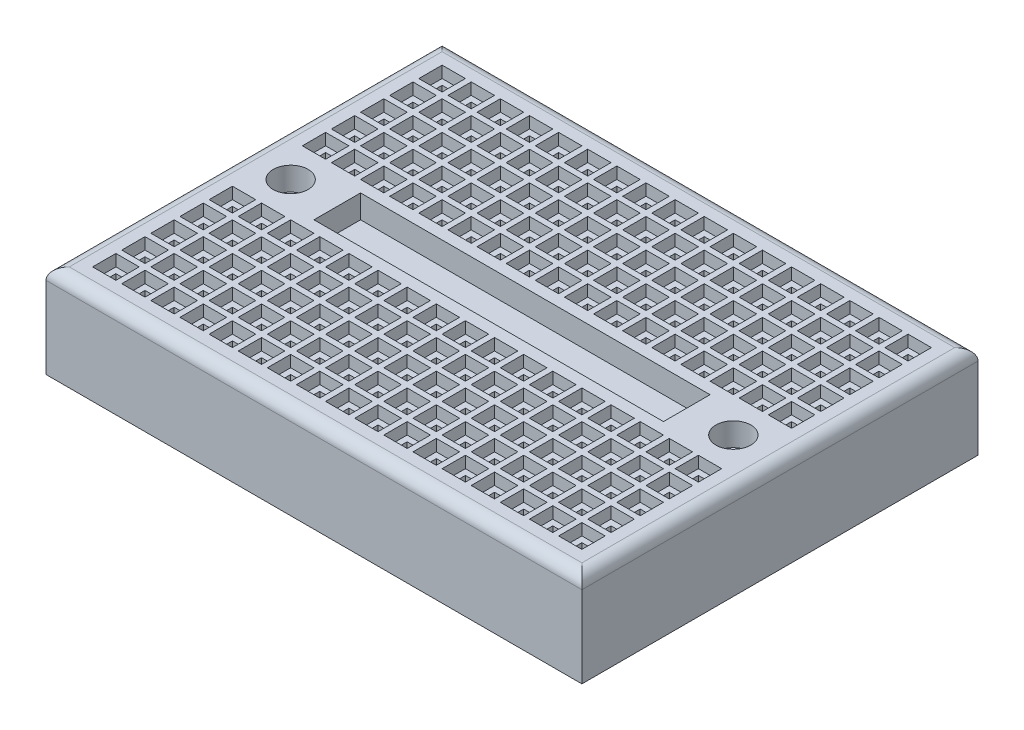
from build123d import *

# Parameters (mm, degrees)
SKETCH1_W           = 46
SKETCH1_H           = 34
BOSS_EXTRUDE1_DEPTH = 8
SKETCH2_W           = 30
SKETCH2_H           = 4
CUT_EXTRUDE1_DEPTH  = 2
SKETCH3_R           = 1.5
CUT_EXTRUDE2_DEPTH  = 2
SKETCH4_R           = 1
CUT_EXTRUDE3_DEPTH  = 12
FILLET1_R           = 1
SKETCH5_W           = 2
SKETCH5_H           = 2
CUT_EXTRUDE4_DEPTH  = 1
SKETCH6_W           = 1
SKETCH6_H           = 1
CUT_EXTRUDE5_DEPTH  = 5


with BuildPart() as part:
    # Sketch1 → Boss-Extrude1 (new body)
    with BuildSketch(Plane(origin=(0, 0, 0), x_dir=(1, 0, 0), z_dir=(0, 1, 0))):
        Rectangle(SKETCH1_W, SKETCH1_H)
    extrude(amount=BOSS_EXTRUDE1_DEPTH)

    # Sketch2 → Cut-Extrude1 (cut)
    with BuildSketch(Plane(origin=(0, 8, 0), x_dir=(1, 0, 0), z_dir=(0, 1, 0))):
        Rectangle(SKETCH2_W, SKETCH2_H)
    extrude(amount=-CUT_EXTRUDE1_DEPTH, mode=Mode.SUBTRACT)

    # Sketch3 → Cut-Extrude2 (cut)
    with BuildSketch(Plane(origin=(0, 8, 0), x_dir=(1, 0, 0), z_dir=(0, 1, 0))):
        with Locations((-19, 0)):
            Circle(SKETCH3_R)
        with Locations((19, 0)):
            Circle(SKETCH3_R)
    extrude(amount=-CUT_EXTRUDE2_DEPTH, mode=Mode.SUBTRACT)

    # Sketch4 → Cut-Extrude3 (cut)
    with BuildSketch(Plane(origin=(0, 6, 0), x_dir=(1, 0, 0), z_dir=(0, 1, 0))):
        with Locations((-19, 0)):
            Circle(SKETCH4_R)
        with Locations((19, 0)):
            Circle(SKETCH4_R)
    extrude(amount=-CUT_EXTRUDE3_DEPTH, mode=Mode.SUBTRACT)

    # Fillet1
    fillet1_edges = [part.edges().sort_by_distance(p)[0] for p in [
        (-23, 8, 0),
        (0, 8, 17),
        (23, 8, 0),
        (0, 8, -17),
    ]]
    fillet(fillet1_edges, radius=FILLET1_R)

    # Sketch5 → Cut-Extrude4 (cut)
    with BuildSketch(Plane(origin=(0, 8, 0), x_dir=(1, 0, 0), z_dir=(0, 1, 0))):
        with Locations((-17.5, 14)):
            Rectangle(SKETCH5_W, SKETCH5_H)
        with Locations((-20, 14)):
            Rectangle(SKETCH5_W, SKETCH5_H)
        with Locations((-15, 14)):
            Rectangle(SKETCH5_W, SKETCH5_H)
        with Locations((-12.5, 14)):
            Rectangle(SKETCH5_W, SKETCH5_H)
        with Locations((-10, 14)):
            Rectangle(SKETCH5_W, SKETCH5_H)
        with Locations((-7.5, 14)):
            Rectangle(SKETCH5_W, SKETCH5_H)
        with Locations((-5, 14)):
            Rectangle(SKETCH5_W, SKETCH5_H)
        with Locations((-2.5, 14)):
            Rectangle(SKETCH5_W, SKETCH5_H)
        with Locations((0, 14)):
            Rectangle(SKETCH5_W, SKETCH5_H)
        with Locations((2.5, 14)):
            Rectangle(SKETCH5_W, SKETCH5_H)
        with Locations((5, 14)):
            Rectangle(SKETCH5_W, SKETCH5_H)
        with Locations((7.5, 14)):
            Rectangle(SKETCH5_W, SKETCH5_H)
        with Locations((10, 14)):
            Rectangle(SKETCH5_W, SKETCH5_H)
        with Locations((12.5, 14)):
            Rectangle(SKETCH5_W, SKETCH5_H)
        with Locations((15, 14)):
            Rectangle(SKETCH5_W, SKETCH5_H)
        with Locations((17.5, 14)):
            Rectangle(SKETCH5_W, SKETCH5_H)
        with Locations((20, 14)):
            Rectangle(SKETCH5_W, SKETCH5_H)
        with Locations((-17.5, 11.5)):
            Rectangle(SKETCH5_W, SKETCH5_H)
        with Locations((-15, 11.5)):
            Rectangle(SKETCH5_W, SKETCH5_H)
        with Locations((-12.5, 11.5)):
            Rectangle(SKETCH5_W, SKETCH5_H)
        with Locations((-10, 11.5)):
            Rectangle(SKETCH5_W, SKETCH5_H)
        with Locations((-7.5, 11.5)):
            Rectangle(SKETCH5_W, SKETCH5_H)
        with Locations((-5, 11.5)):
            Rectangle(SKETCH5_W, SKETCH5_H)
        with Locations((-2.5, 11.5)):
            Rectangle(SKETCH5_W, SKETCH5_H)
        with Locations((0, 11.5)):
            Rectangle(SKETCH5_W, SKETCH5_H)
        with Locations((2.5, 11.5)):
            Rectangle(SKETCH5_W, SKETCH5_H)
        with Locations((5, 11.5)):
            Rectangle(SKETCH5_W, SKETCH5_H)
        with Locations((7.5, 11.5)):
            Rectangle(SKETCH5_W, SKETCH5_H)
        with Locations((10, 11.5)):
            Rectangle(SKETCH5_W, SKETCH5_H)
        with Locations((12.5, 11.5)):
            Rectangle(SKETCH5_W, SKETCH5_H)
        with Locations((15, 11.5)):
            Rectangle(SKETCH5_W, SKETCH5_H)
        with Locations((17.5, 11.5)):
            Rectangle(SKETCH5_W, SKETCH5_H)
        with Locations((20, 11.5)):
            Rectangle(SKETCH5_W, SKETCH5_H)
        with Locations((-17.5, 9)):
            Rectangle(SKETCH5_W, SKETCH5_H)
        with Locations((-15, 9)):
            Rectangle(SKETCH5_W, SKETCH5_H)
        with Locations((-12.5, 9)):
            Rectangle(SKETCH5_W, SKETCH5_H)
        with Locations((-10, 9)):
            Rectangle(SKETCH5_W, SKETCH5_H)
        with Locations((-7.5, 9)):
            Rectangle(SKETCH5_W, SKETCH5_H)
        with Locations((-5, 9)):
            Rectangle(SKETCH5_W, SKETCH5_H)
        with Locations((-2.5, 9)):
            Rectangle(SKETCH5_W, SKETCH5_H)
        with Locations((0, 9)):
            Rectangle(SKETCH5_W, SKETCH5_H)
        with Locations((2.5, 9)):
            Rectangle(SKETCH5_W, SKETCH5_H)
        with Locations((5, 9)):
            Rectangle(SKETCH5_W, SKETCH5_H)
        with Locations((7.5, 9)):
            Rectangle(SKETCH5_W, SKETCH5_H)
        with Locations((10, 9)):
            Rectangle(SKETCH5_W, SKETCH5_H)
        with Locations((12.5, 9)):
            Rectangle(SKETCH5_W, SKETCH5_H)
        with Locations((15, 9)):
            Rectangle(SKETCH5_W, SKETCH5_H)
        with Locations((17.5, 9)):
            Rectangle(SKETCH5_W, SKETCH5_H)
        with Locations((20, 9)):
            Rectangle(SKETCH5_W, SKETCH5_H)
        with Locations((-17.5, 6.5)):
            Rectangle(SKETCH5_W, SKETCH5_H)
        with Locations((-15, 6.5)):
            Rectangle(SKETCH5_W, SKETCH5_H)
        with Locations((-12.5, 6.5)):
            Rectangle(SKETCH5_W, SKETCH5_H)
        with Locations((-10, 6.5)):
            Rectangle(SKETCH5_W, SKETCH5_H)
        with Locations((-7.5, 6.5)):
            Rectangle(SKETCH5_W, SKETCH5_H)
        with Locations((-5, 6.5)):
            Rectangle(SKETCH5_W, SKETCH5_H)
        with Locations((-2.5, 6.5)):
            Rectangle(SKETCH5_W, SKETCH5_H)
        with Locations((0, 6.5)):
            Rectangle(SKETCH5_W, SKETCH5_H)
        with Locations((2.5, 6.5)):
            Rectangle(SKETCH5_W, SKETCH5_H)
        with Locations((5, 6.5)):
            Rectangle(SKETCH5_W, SKETCH5_H)
        with Locations((7.5, 6.5)):
            Rectangle(SKETCH5_W, SKETCH5_H)
        with Locations((10, 6.5)):
            Rectangle(SKETCH5_W, SKETCH5_H)
        with Locations((12.5, 6.5)):
            Rectangle(SKETCH5_W, SKETCH5_H)
        with Locations((15, 6.5)):
            Rectangle(SKETCH5_W, SKETCH5_H)
        with Locations((17.5, 6.5)):
            Rectangle(SKETCH5_W, SKETCH5_H)
        with Locations((20, 6.5)):
            Rectangle(SKETCH5_W, SKETCH5_H)
        with Locations((-17.5, 4)):
            Rectangle(SKETCH5_W, SKETCH5_H)
        with Locations((-15, 4)):
            Rectangle(SKETCH5_W, SKETCH5_H)
        with Locations((-12.5, 4)):
            Rectangle(SKETCH5_W, SKETCH5_H)
        with Locations((-10, 4)):
            Rectangle(SKETCH5_W, SKETCH5_H)
        with Locations((-7.5, 4)):
            Rectangle(SKETCH5_W, SKETCH5_H)
        with Locations((-5, 4)):
            Rectangle(SKETCH5_W, SKETCH5_H)
        with Locations((-2.5, 4)):
            Rectangle(SKETCH5_W, SKETCH5_H)
        with Locations((0, 4)):
            Rectangle(SKETCH5_W, SKETCH5_H)
        with Locations((2.5, 4)):
            Rectangle(SKETCH5_W, SKETCH5_H)
        with Locations((5, 4)):
            Rectangle(SKETCH5_W, SKETCH5_H)
        with Locations((7.5, 4)):
            Rectangle(SKETCH5_W, SKETCH5_H)
        with Locations((10, 4)):
            Rectangle(SKETCH5_W, SKETCH5_H)
        with Locations((12.5, 4)):
            Rectangle(SKETCH5_W, SKETCH5_H)
        with Locations((15, 4)):
            Rectangle(SKETCH5_W, SKETCH5_H)
        with Locations((17.5, 4)):
            Rectangle(SKETCH5_W, SKETCH5_H)
        with Locations((20, 4)):
            Rectangle(SKETCH5_W, SKETCH5_H)
        with Locations((-20, 11.5)):
            Rectangle(SKETCH5_W, SKETCH5_H)
        with Locations((-20, 9)):
            Rectangle(SKETCH5_W, SKETCH5_H)
        with Locations((-20, 6.5)):
            Rectangle(SKETCH5_W, SKETCH5_H)
        with Locations((-20, 4)):
            Rectangle(SKETCH5_W, SKETCH5_H)
        with Locations((-20, -4)):
            Rectangle(SKETCH5_W, SKETCH5_H)
        with Locations((-20, -6.5)):
            Rectangle(SKETCH5_W, SKETCH5_H)
        with Locations((-20, -9)):
            Rectangle(SKETCH5_W, SKETCH5_H)
        with Locations((-20, -11.5)):
            Rectangle(SKETCH5_W, SKETCH5_H)
        with Locations((20, -4)):
            Rectangle(SKETCH5_W, SKETCH5_H)
        with Locations((17.5, -4)):
            Rectangle(SKETCH5_W, SKETCH5_H)
        with Locations((15, -4)):
            Rectangle(SKETCH5_W, SKETCH5_H)
        with Locations((12.5, -4)):
            Rectangle(SKETCH5_W, SKETCH5_H)
        with Locations((10, -4)):
            Rectangle(SKETCH5_W, SKETCH5_H)
        with Locations((7.5, -4)):
            Rectangle(SKETCH5_W, SKETCH5_H)
        with Locations((5, -4)):
            Rectangle(SKETCH5_W, SKETCH5_H)
        with Locations((2.5, -4)):
            Rectangle(SKETCH5_W, SKETCH5_H)
        with Locations((0, -4)):
            Rectangle(SKETCH5_W, SKETCH5_H)
        with Locations((-2.5, -4)):
            Rectangle(SKETCH5_W, SKETCH5_H)
        with Locations((-5, -4)):
            Rectangle(SKETCH5_W, SKETCH5_H)
        with Locations((-7.5, -4)):
            Rectangle(SKETCH5_W, SKETCH5_H)
        with Locations((-10, -4)):
            Rectangle(SKETCH5_W, SKETCH5_H)
        with Locations((-12.5, -4)):
            Rectangle(SKETCH5_W, SKETCH5_H)
        with Locations((-15, -4)):
            Rectangle(SKETCH5_W, SKETCH5_H)
        with Locations((-17.5, -4)):
            Rectangle(SKETCH5_W, SKETCH5_H)
        with Locations((20, -6.5)):
            Rectangle(SKETCH5_W, SKETCH5_H)
        with Locations((17.5, -6.5)):
            Rectangle(SKETCH5_W, SKETCH5_H)
        with Locations((15, -6.5)):
            Rectangle(SKETCH5_W, SKETCH5_H)
        with Locations((12.5, -6.5)):
            Rectangle(SKETCH5_W, SKETCH5_H)
        with Locations((10, -6.5)):
            Rectangle(SKETCH5_W, SKETCH5_H)
        with Locations((7.5, -6.5)):
            Rectangle(SKETCH5_W, SKETCH5_H)
        with Locations((5, -6.5)):
            Rectangle(SKETCH5_W, SKETCH5_H)
        with Locations((2.5, -6.5)):
            Rectangle(SKETCH5_W, SKETCH5_H)
        with Locations((0, -6.5)):
            Rectangle(SKETCH5_W, SKETCH5_H)
        with Locations((-2.5, -6.5)):
            Rectangle(SKETCH5_W, SKETCH5_H)
        with Locations((-5, -6.5)):
            Rectangle(SKETCH5_W, SKETCH5_H)
        with Locations((-7.5, -6.5)):
            Rectangle(SKETCH5_W, SKETCH5_H)
        with Locations((-10, -6.5)):
            Rectangle(SKETCH5_W, SKETCH5_H)
        with Locations((-12.5, -6.5)):
            Rectangle(SKETCH5_W, SKETCH5_H)
        with Locations((-15, -6.5)):
            Rectangle(SKETCH5_W, SKETCH5_H)
        with Locations((-17.5, -6.5)):
            Rectangle(SKETCH5_W, SKETCH5_H)
        with Locations((20, -9)):
            Rectangle(SKETCH5_W, SKETCH5_H)
        with Locations((17.5, -9)):
            Rectangle(SKETCH5_W, SKETCH5_H)
        with Locations((15, -9)):
            Rectangle(SKETCH5_W, SKETCH5_H)
        with Locations((12.5, -9)):
            Rectangle(SKETCH5_W, SKETCH5_H)
        with Locations((10, -9)):
            Rectangle(SKETCH5_W, SKETCH5_H)
        with Locations((7.5, -9)):
            Rectangle(SKETCH5_W, SKETCH5_H)
        with Locations((5, -9)):
            Rectangle(SKETCH5_W, SKETCH5_H)
        with Locations((2.5, -9)):
            Rectangle(SKETCH5_W, SKETCH5_H)
        with Locations((0, -9)):
            Rectangle(SKETCH5_W, SKETCH5_H)
        with Locations((-2.5, -9)):
            Rectangle(SKETCH5_W, SKETCH5_H)
        with Locations((-5, -9)):
            Rectangle(SKETCH5_W, SKETCH5_H)
        with Locations((-7.5, -9)):
            Rectangle(SKETCH5_W, SKETCH5_H)
        with Locations((-10, -9)):
            Rectangle(SKETCH5_W, SKETCH5_H)
        with Locations((-12.5, -9)):
            Rectangle(SKETCH5_W, SKETCH5_H)
        with Locations((-15, -9)):
            Rectangle(SKETCH5_W, SKETCH5_H)
        with Locations((-17.5, -9)):
            Rectangle(SKETCH5_W, SKETCH5_H)
        with Locations((20, -11.5)):
            Rectangle(SKETCH5_W, SKETCH5_H)
        with Locations((17.5, -11.5)):
            Rectangle(SKETCH5_W, SKETCH5_H)
        with Locations((15, -11.5)):
            Rectangle(SKETCH5_W, SKETCH5_H)
        with Locations((12.5, -11.5)):
            Rectangle(SKETCH5_W, SKETCH5_H)
        with Locations((10, -11.5)):
            Rectangle(SKETCH5_W, SKETCH5_H)
        with Locations((7.5, -11.5)):
            Rectangle(SKETCH5_W, SKETCH5_H)
        with Locations((5, -11.5)):
            Rectangle(SKETCH5_W, SKETCH5_H)
        with Locations((2.5, -11.5)):
            Rectangle(SKETCH5_W, SKETCH5_H)
        with Locations((0, -11.5)):
            Rectangle(SKETCH5_W, SKETCH5_H)
        with Locations((-2.5, -11.5)):
            Rectangle(SKETCH5_W, SKETCH5_H)
        with Locations((-5, -11.5)):
            Rectangle(SKETCH5_W, SKETCH5_H)
        with Locations((-7.5, -11.5)):
            Rectangle(SKETCH5_W, SKETCH5_H)
        with Locations((-10, -11.5)):
            Rectangle(SKETCH5_W, SKETCH5_H)
        with Locations((-12.5, -11.5)):
            Rectangle(SKETCH5_W, SKETCH5_H)
        with Locations((-15, -11.5)):
            Rectangle(SKETCH5_W, SKETCH5_H)
        with Locations((-17.5, -11.5)):
            Rectangle(SKETCH5_W, SKETCH5_H)
        with Locations((20, -14)):
            Rectangle(SKETCH5_W, SKETCH5_H)
        with Locations((17.5, -14)):
            Rectangle(SKETCH5_W, SKETCH5_H)
        with Locations((15, -14)):
            Rectangle(SKETCH5_W, SKETCH5_H)
        with Locations((12.5, -14)):
            Rectangle(SKETCH5_W, SKETCH5_H)
        with Locations((10, -14)):
            Rectangle(SKETCH5_W, SKETCH5_H)
        with Locations((7.5, -14)):
            Rectangle(SKETCH5_W, SKETCH5_H)
        with Locations((5, -14)):
            Rectangle(SKETCH5_W, SKETCH5_H)
        with Locations((2.5, -14)):
            Rectangle(SKETCH5_W, SKETCH5_H)
        with Locations((0, -14)):
            Rectangle(SKETCH5_W, SKETCH5_H)
        with Locations((-2.5, -14)):
            Rectangle(SKETCH5_W, SKETCH5_H)
        with Locations((-5, -14)):
            Rectangle(SKETCH5_W, SKETCH5_H)
        with Locations((-7.5, -14)):
            Rectangle(SKETCH5_W, SKETCH5_H)
        with Locations((-10, -14)):
            Rectangle(SKETCH5_W, SKETCH5_H)
        with Locations((-12.5, -14)):
            Rectangle(SKETCH5_W, SKETCH5_H)
        with Locations((-15, -14)):
            Rectangle(SKETCH5_W, SKETCH5_H)
        with Locations((-17.5, -14)):
            Rectangle(SKETCH5_W, SKETCH5_H)
        with Locations((-20, -14)):
            Rectangle(SKETCH5_W, SKETCH5_H)
    extrude(amount=-CUT_EXTRUDE4_DEPTH, mode=Mode.SUBTRACT)

    # Sketch6 → Cut-Extrude5 (cut)
    with BuildSketch(Plane(origin=(0, 7, 0), x_dir=(1, 0, 0), z_dir=(0, 1, 0))):
        with Locations((-17.5, 14)):
            Rectangle(SKETCH6_W, SKETCH6_H)
        with Locations((-20, 14)):
            Rectangle(SKETCH6_W, SKETCH6_H)
        with Locations((-15, 14)):
            Rectangle(SKETCH6_W, SKETCH6_H)
        with Locations((-12.5, 14)):
            Rectangle(SKETCH6_W, SKETCH6_H)
        with Locations((-10, 14)):
            Rectangle(SKETCH6_W, SKETCH6_H)
        with Locations((-7.5, 14)):
            Rectangle(SKETCH6_W, SKETCH6_H)
        with Locations((-5, 14)):
            Rectangle(SKETCH6_W, SKETCH6_H)
        with Locations((-2.5, 14)):
            Rectangle(SKETCH6_W, SKETCH6_H)
        with Locations((0, 14)):
            Rectangle(SKETCH6_W, SKETCH6_H)
        with Locations((2.5, 14)):
            Rectangle(SKETCH6_W, SKETCH6_H)
        with Locations((5, 14)):
            Rectangle(SKETCH6_W, SKETCH6_H)
        with Locations((7.5, 14)):
            Rectangle(SKETCH6_W, SKETCH6_H)
        with Locations((10, 14)):
            Rectangle(SKETCH6_W, SKETCH6_H)
        with Locations((12.5, 14)):
            Rectangle(SKETCH6_W, SKETCH6_H)
        with Locations((15, 14)):
            Rectangle(SKETCH6_W, SKETCH6_H)
        with Locations((17.5, 14)):
            Rectangle(SKETCH6_W, SKETCH6_H)
        with Locations((20, 14)):
            Rectangle(SKETCH6_W, SKETCH6_H)
        with Locations((-17.5, 11.5)):
            Rectangle(SKETCH6_W, SKETCH6_H)
        with Locations((-15, 11.5)):
            Rectangle(SKETCH6_W, SKETCH6_H)
        with Locations((-12.5, 11.5)):
            Rectangle(SKETCH6_W, SKETCH6_H)
        with Locations((-10, 11.5)):
            Rectangle(SKETCH6_W, SKETCH6_H)
        with Locations((-7.5, 11.5)):
            Rectangle(SKETCH6_W, SKETCH6_H)
        with Locations((-5, 11.5)):
            Rectangle(SKETCH6_W, SKETCH6_H)
        with Locations((-2.5, 11.5)):
            Rectangle(SKETCH6_W, SKETCH6_H)
        with Locations((0, 11.5)):
            Rectangle(SKETCH6_W, SKETCH6_H)
        with Locations((2.5, 11.5)):
            Rectangle(SKETCH6_W, SKETCH6_H)
        with Locations((5, 11.5)):
            Rectangle(SKETCH6_W, SKETCH6_H)
        with Locations((7.5, 11.5)):
            Rectangle(SKETCH6_W, SKETCH6_H)
        with Locations((10, 11.5)):
            Rectangle(SKETCH6_W, SKETCH6_H)
        with Locations((12.5, 11.5)):
            Rectangle(SKETCH6_W, SKETCH6_H)
        with Locations((15, 11.5)):
            Rectangle(SKETCH6_W, SKETCH6_H)
        with Locations((17.5, 11.5)):
            Rectangle(SKETCH6_W, SKETCH6_H)
        with Locations((20, 11.5)):
            Rectangle(SKETCH6_W, SKETCH6_H)
        with Locations((-17.5, 9)):
            Rectangle(SKETCH6_W, SKETCH6_H)
        with Locations((-15, 9)):
            Rectangle(SKETCH6_W, SKETCH6_H)
        with Locations((-12.5, 9)):
            Rectangle(SKETCH6_W, SKETCH6_H)
        with Locations((-10, 9)):
            Rectangle(SKETCH6_W, SKETCH6_H)
        with Locations((-7.5, 9)):
            Rectangle(SKETCH6_W, SKETCH6_H)
        with Locations((-5, 9)):
            Rectangle(SKETCH6_W, SKETCH6_H)
        with Locations((-2.5, 9)):
            Rectangle(SKETCH6_W, SKETCH6_H)
        with Locations((0, 9)):
            Rectangle(SKETCH6_W, SKETCH6_H)
        with Locations((2.5, 9)):
            Rectangle(SKETCH6_W, SKETCH6_H)
        with Locations((5, 9)):
            Rectangle(SKETCH6_W, SKETCH6_H)
        with Locations((7.5, 9)):
            Rectangle(SKETCH6_W, SKETCH6_H)
        with Locations((10, 9)):
            Rectangle(SKETCH6_W, SKETCH6_H)
        with Locations((12.5, 9)):
            Rectangle(SKETCH6_W, SKETCH6_H)
        with Locations((15, 9)):
            Rectangle(SKETCH6_W, SKETCH6_H)
        with Locations((17.5, 9)):
            Rectangle(SKETCH6_W, SKETCH6_H)
        with Locations((20, 9)):
            Rectangle(SKETCH6_W, SKETCH6_H)
        with Locations((-17.5, 6.5)):
            Rectangle(SKETCH6_W, SKETCH6_H)
        with Locations((-15, 6.5)):
            Rectangle(SKETCH6_W, SKETCH6_H)
        with Locations((-12.5, 6.5)):
            Rectangle(SKETCH6_W, SKETCH6_H)
        with Locations((-10, 6.5)):
            Rectangle(SKETCH6_W, SKETCH6_H)
        with Locations((-7.5, 6.5)):
            Rectangle(SKETCH6_W, SKETCH6_H)
        with Locations((-5, 6.5)):
            Rectangle(SKETCH6_W, SKETCH6_H)
        with Locations((-2.5, 6.5)):
            Rectangle(SKETCH6_W, SKETCH6_H)
        with Locations((0, 6.5)):
            Rectangle(SKETCH6_W, SKETCH6_H)
        with Locations((2.5, 6.5)):
            Rectangle(SKETCH6_W, SKETCH6_H)
        with Locations((5, 6.5)):
            Rectangle(SKETCH6_W, SKETCH6_H)
        with Locations((7.5, 6.5)):
            Rectangle(SKETCH6_W, SKETCH6_H)
        with Locations((10, 6.5)):
            Rectangle(SKETCH6_W, SKETCH6_H)
        with Locations((12.5, 6.5)):
            Rectangle(SKETCH6_W, SKETCH6_H)
        with Locations((15, 6.5)):
            Rectangle(SKETCH6_W, SKETCH6_H)
        with Locations((17.5, 6.5)):
            Rectangle(SKETCH6_W, SKETCH6_H)
        with Locations((20, 6.5)):
            Rectangle(SKETCH6_W, SKETCH6_H)
        with Locations((-17.5, 4)):
            Rectangle(SKETCH6_W, SKETCH6_H)
        with Locations((-15, 4)):
            Rectangle(SKETCH6_W, SKETCH6_H)
        with Locations((-12.5, 4)):
            Rectangle(SKETCH6_W, SKETCH6_H)
        with Locations((-10, 4)):
            Rectangle(SKETCH6_W, SKETCH6_H)
        with Locations((-7.5, 4)):
            Rectangle(SKETCH6_W, SKETCH6_H)
        with Locations((-5, 4)):
            Rectangle(SKETCH6_W, SKETCH6_H)
        with Locations((-2.5, 4)):
            Rectangle(SKETCH6_W, SKETCH6_H)
        with Locations((0, 4)):
            Rectangle(SKETCH6_W, SKETCH6_H)
        with Locations((2.5, 4)):
            Rectangle(SKETCH6_W, SKETCH6_H)
        with Locations((5, 4)):
            Rectangle(SKETCH6_W, SKETCH6_H)
        with Locations((7.5, 4)):
            Rectangle(SKETCH6_W, SKETCH6_H)
        with Locations((10, 4)):
            Rectangle(SKETCH6_W, SKETCH6_H)
        with Locations((12.5, 4)):
            Rectangle(SKETCH6_W, SKETCH6_H)
        with Locations((15, 4)):
            Rectangle(SKETCH6_W, SKETCH6_H)
        with Locations((17.5, 4)):
            Rectangle(SKETCH6_W, SKETCH6_H)
        with Locations((20, 4)):
            Rectangle(SKETCH6_W, SKETCH6_H)
        with Locations((-20, 11.5)):
            Rectangle(SKETCH6_W, SKETCH6_H)
        with Locations((-20, 9)):
            Rectangle(SKETCH6_W, SKETCH6_H)
        with Locations((-20, 6.5)):
            Rectangle(SKETCH6_W, SKETCH6_H)
        with Locations((-20, 4)):
            Rectangle(SKETCH6_W, SKETCH6_H)
        with Locations((-20, -4)):
            Rectangle(SKETCH6_W, SKETCH6_H)
        with Locations((-20, -6.5)):
            Rectangle(SKETCH6_W, SKETCH6_H)
        with Locations((-20, -9)):
            Rectangle(SKETCH6_W, SKETCH6_H)
        with Locations((-20, -11.5)):
            Rectangle(SKETCH6_W, SKETCH6_H)
        with Locations((20, -4)):
            Rectangle(SKETCH6_W, SKETCH6_H)
        with Locations((17.5, -4)):
            Rectangle(SKETCH6_W, SKETCH6_H)
        with Locations((15, -4)):
            Rectangle(SKETCH6_W, SKETCH6_H)
        with Locations((12.5, -4)):
            Rectangle(SKETCH6_W, SKETCH6_H)
        with Locations((10, -4)):
            Rectangle(SKETCH6_W, SKETCH6_H)
        with Locations((7.5, -4)):
            Rectangle(SKETCH6_W, SKETCH6_H)
        with Locations((5, -4)):
            Rectangle(SKETCH6_W, SKETCH6_H)
        with Locations((2.5, -4)):
            Rectangle(SKETCH6_W, SKETCH6_H)
        with Locations((0, -4)):
            Rectangle(SKETCH6_W, SKETCH6_H)
        with Locations((-2.5, -4)):
            Rectangle(SKETCH6_W, SKETCH6_H)
        with Locations((-5, -4)):
            Rectangle(SKETCH6_W, SKETCH6_H)
        with Locations((-7.5, -4)):
            Rectangle(SKETCH6_W, SKETCH6_H)
        with Locations((-10, -4)):
            Rectangle(SKETCH6_W, SKETCH6_H)
        with Locations((-12.5, -4)):
            Rectangle(SKETCH6_W, SKETCH6_H)
        with Locations((-15, -4)):
            Rectangle(SKETCH6_W, SKETCH6_H)
        with Locations((-17.5, -4)):
            Rectangle(SKETCH6_W, SKETCH6_H)
        with Locations((20, -6.5)):
            Rectangle(SKETCH6_W, SKETCH6_H)
        with Locations((17.5, -6.5)):
            Rectangle(SKETCH6_W, SKETCH6_H)
        with Locations((15, -6.5)):
            Rectangle(SKETCH6_W, SKETCH6_H)
        with Locations((12.5, -6.5)):
            Rectangle(SKETCH6_W, SKETCH6_H)
        with Locations((10, -6.5)):
            Rectangle(SKETCH6_W, SKETCH6_H)
        with Locations((7.5, -6.5)):
            Rectangle(SKETCH6_W, SKETCH6_H)
        with Locations((5, -6.5)):
            Rectangle(SKETCH6_W, SKETCH6_H)
        with Locations((2.5, -6.5)):
            Rectangle(SKETCH6_W, SKETCH6_H)
        with Locations((0, -6.5)):
            Rectangle(SKETCH6_W, SKETCH6_H)
        with Locations((-2.5, -6.5)):
            Rectangle(SKETCH6_W, SKETCH6_H)
        with Locations((-5, -6.5)):
            Rectangle(SKETCH6_W, SKETCH6_H)
        with Locations((-7.5, -6.5)):
            Rectangle(SKETCH6_W, SKETCH6_H)
        with Locations((-10, -6.5)):
            Rectangle(SKETCH6_W, SKETCH6_H)
        with Locations((-12.5, -6.5)):
            Rectangle(SKETCH6_W, SKETCH6_H)
        with Locations((-15, -6.5)):
            Rectangle(SKETCH6_W, SKETCH6_H)
        with Locations((-17.5, -6.5)):
            Rectangle(SKETCH6_W, SKETCH6_H)
        with Locations((20, -9)):
            Rectangle(SKETCH6_W, SKETCH6_H)
        with Locations((17.5, -9)):
            Rectangle(SKETCH6_W, SKETCH6_H)
        with Locations((15, -9)):
            Rectangle(SKETCH6_W, SKETCH6_H)
        with Locations((12.5, -9)):
            Rectangle(SKETCH6_W, SKETCH6_H)
        with Locations((10, -9)):
            Rectangle(SKETCH6_W, SKETCH6_H)
        with Locations((7.5, -9)):
            Rectangle(SKETCH6_W, SKETCH6_H)
        with Locations((5, -9)):
            Rectangle(SKETCH6_W, SKETCH6_H)
        with Locations((2.5, -9)):
            Rectangle(SKETCH6_W, SKETCH6_H)
        with Locations((0, -9)):
            Rectangle(SKETCH6_W, SKETCH6_H)
        with Locations((-2.5, -9)):
            Rectangle(SKETCH6_W, SKETCH6_H)
        with Locations((-5, -9)):
            Rectangle(SKETCH6_W, SKETCH6_H)
        with Locations((-7.5, -9)):
            Rectangle(SKETCH6_W, SKETCH6_H)
        with Locations((-10, -9)):
            Rectangle(SKETCH6_W, SKETCH6_H)
        with Locations((-12.5, -9)):
            Rectangle(SKETCH6_W, SKETCH6_H)
        with Locations((-15, -9)):
            Rectangle(SKETCH6_W, SKETCH6_H)
        with Locations((-17.5, -9)):
            Rectangle(SKETCH6_W, SKETCH6_H)
        with Locations((20, -11.5)):
            Rectangle(SKETCH6_W, SKETCH6_H)
        with Locations((17.5, -11.5)):
            Rectangle(SKETCH6_W, SKETCH6_H)
        with Locations((15, -11.5)):
            Rectangle(SKETCH6_W, SKETCH6_H)
        with Locations((12.5, -11.5)):
            Rectangle(SKETCH6_W, SKETCH6_H)
        with Locations((10, -11.5)):
            Rectangle(SKETCH6_W, SKETCH6_H)
        with Locations((7.5, -11.5)):
            Rectangle(SKETCH6_W, SKETCH6_H)
        with Locations((5, -11.5)):
            Rectangle(SKETCH6_W, SKETCH6_H)
        with Locations((2.5, -11.5)):
            Rectangle(SKETCH6_W, SKETCH6_H)
        with Locations((0, -11.5)):
            Rectangle(SKETCH6_W, SKETCH6_H)
        with Locations((-2.5, -11.5)):
            Rectangle(SKETCH6_W, SKETCH6_H)
        with Locations((-5, -11.5)):
            Rectangle(SKETCH6_W, SKETCH6_H)
        with Locations((-7.5, -11.5)):
            Rectangle(SKETCH6_W, SKETCH6_H)
        with Locations((-10, -11.5)):
            Rectangle(SKETCH6_W, SKETCH6_H)
        with Locations((-12.5, -11.5)):
            Rectangle(SKETCH6_W, SKETCH6_H)
        with Locations((-15, -11.5)):
            Rectangle(SKETCH6_W, SKETCH6_H)
        with Locations((-17.5, -11.5)):
            Rectangle(SKETCH6_W, SKETCH6_H)
        with Locations((20, -14)):
            Rectangle(SKETCH6_W, SKETCH6_H)
        with Locations((17.5, -14)):
            Rectangle(SKETCH6_W, SKETCH6_H)
        with Locations((15, -14)):
            Rectangle(SKETCH6_W, SKETCH6_H)
        with Locations((12.5, -14)):
            Rectangle(SKETCH6_W, SKETCH6_H)
        with Locations((10, -14)):
            Rectangle(SKETCH6_W, SKETCH6_H)
        with Locations((7.5, -14)):
            Rectangle(SKETCH6_W, SKETCH6_H)
        with Locations((5, -14)):
            Rectangle(SKETCH6_W, SKETCH6_H)
        with Locations((2.5, -14)):
            Rectangle(SKETCH6_W, SKETCH6_H)
        with Locations((0, -14)):
            Rectangle(SKETCH6_W, SKETCH6_H)
        with Locations((-2.5, -14)):
            Rectangle(SKETCH6_W, SKETCH6_H)
        with Locations((-5, -14)):
            Rectangle(SKETCH6_W, SKETCH6_H)
        with Locations((-7.5, -14)):
            Rectangle(SKETCH6_W, SKETCH6_H)
        with Locations((-10, -14)):
            Rectangle(SKETCH6_W, SKETCH6_H)
        with Locations((-12.5, -14)):
            Rectangle(SKETCH6_W, SKETCH6_H)
        with Locations((-15, -14)):
            Rectangle(SKETCH6_W, SKETCH6_H)
        with Locations((-17.5, -14)):
            Rectangle(SKETCH6_W, SKETCH6_H)
        with Locations((-20, -14)):
            Rectangle(SKETCH6_W, SKETCH6_H)
    extrude(amount=-CUT_EXTRUDE5_DEPTH, mode=Mode.SUBTRACT)


solid = part.part
